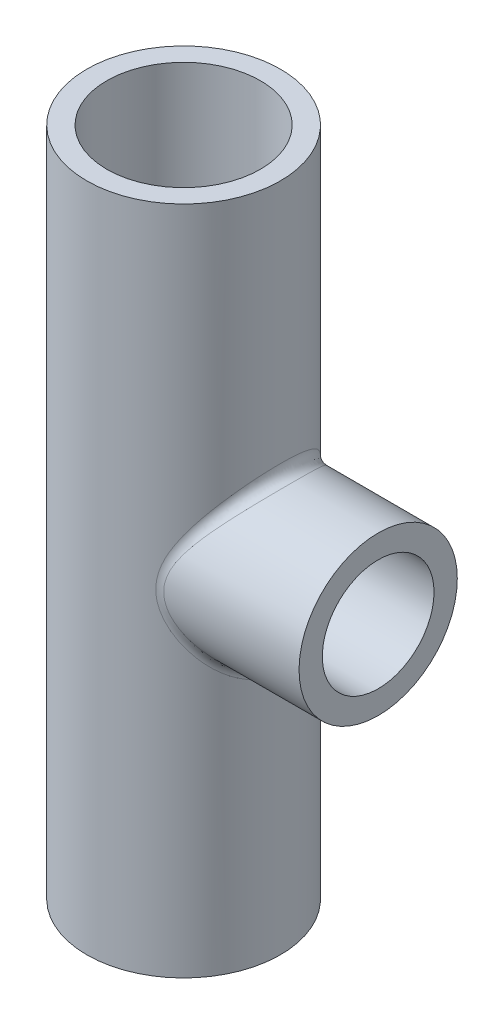
from build123d import *

# Parameters (mm, degrees)
SKETCH1_R           = 10.4
BOSS_EXTRUDE1_DEPTH = 72
SKETCH2_R           = 8.5
BOSS_EXTRUDE2_DEPTH = 20.9
SKETCH5_R           = 6
CUT_EXTRUDE1_DEPTH  = 20.9
SKETCH6_R           = 8.25
CUT_EXTRUDE2_DEPTH  = 73.0000001
FILLET1_R           = 1.2
FILLET2_R           = 1.2


with BuildPart() as part:
    # Sketch1 → Boss-Extrude1 (new body)
    with BuildSketch(Plane(origin=(0, 0, 0), x_dir=(1, 0, 0), z_dir=(0, 1, 0))):
        Circle(SKETCH1_R)
    extrude(amount=BOSS_EXTRUDE1_DEPTH)

    # Sketch2 → Boss-Extrude2 (add)
    with BuildSketch(Plane(origin=(0, 0, 0), x_dir=(0, 0, -1), z_dir=(1, 0, 0))):
        with Locations((0, 36)):
            Circle(SKETCH2_R)
    extrude(amount=BOSS_EXTRUDE2_DEPTH)

    # Sketch5 → Cut-Extrude1 (cut)
    with BuildSketch(Plane(origin=(20.9, 0, 0), x_dir=(0, 0, -1), z_dir=(1, 0, 0))):
        with Locations((0, 36)):
            Circle(SKETCH5_R)
    extrude(amount=-CUT_EXTRUDE1_DEPTH, mode=Mode.SUBTRACT)

    # Sketch6 → Cut-Extrude2 (cut, through all)
    with BuildSketch(Plane(origin=(0, 72, 0), x_dir=(1, 0, 0), z_dir=(0, 1, 0))):
        Circle(SKETCH6_R)
    extrude(amount=-CUT_EXTRUDE2_DEPTH, mode=Mode.SUBTRACT)

    # Fillet1
    fillet1_edges = [part.edges().sort_by_distance(p)[0] for p in [
        (8.4457709, 30.048441702, -6.068686344),
    ]]
    fillet(fillet1_edges, radius=FILLET1_R)

    # Fillet2
    fillet2_edges = [part.edges().sort_by_distance(p)[0] for p in [
        (5.662375826, 36, 6),
    ]]
    fillet(fillet2_edges, radius=FILLET2_R)


solid = part.part
